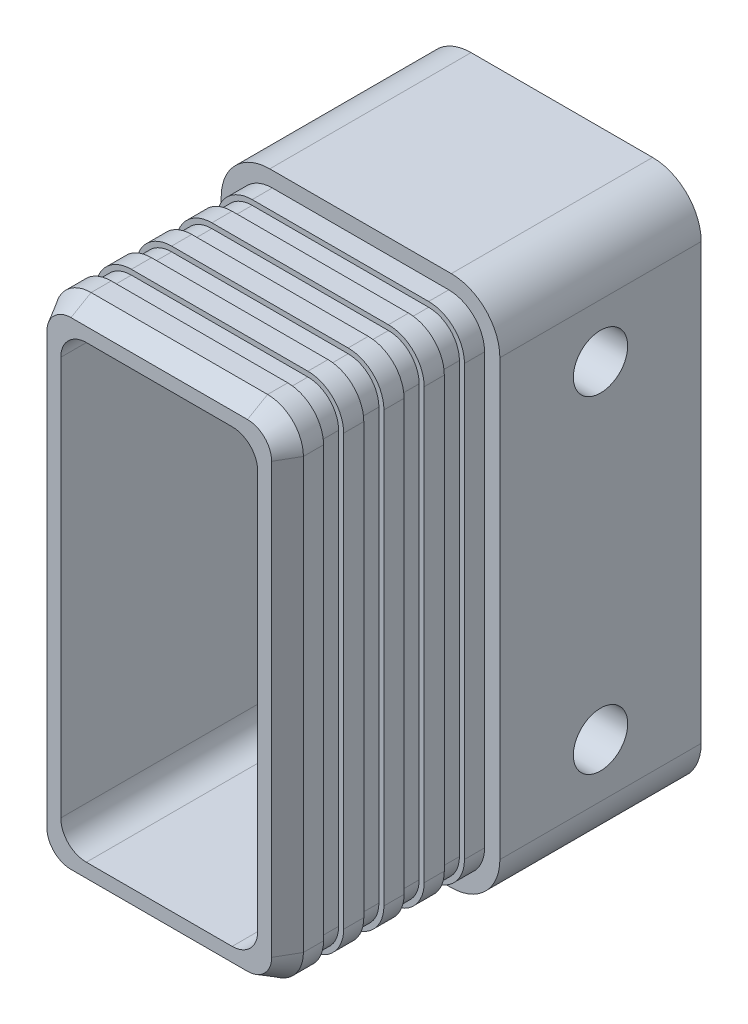
from build123d import *
from OCP.BRepFilletAPI import BRepFilletAPI_MakeChamfer

# Parameters (mm, degrees)
SKETCH1_W             = 24.646
SKETCH1_H             = 49.792
BOSS_EXTRUDE1_DEPTH   = 20
SKETCH2_W             = 27.686
SKETCH2_H             = 52.832
BOSS_EXTRUDE2_DEPTH   = 20
FILLET1_R             = 3.556
FILLET2_R             = 4.826
F_5_0MM_DOWEL_HOLE2_D = 5.4
CUT_EXTRUDE1_DEPTH    = 50.894225167
CUT_EXTRUDE2_START    = -4
CUT_EXTRUDE2_DEPTH    = 2
LPATTERN1_COUNT       = 4
LPATTERN1_PITCH       = 4
CHAMFER1_SIZE         = 2
CHAMFER1_SIZE2        = 1.154700538


with BuildPart() as part:
    # Sketch1 → Boss-Extrude1 (new body)
    with BuildSketch(Plane.XY):
        Rectangle(SKETCH1_W, SKETCH1_H)
    extrude(amount=BOSS_EXTRUDE1_DEPTH)

    # Sketch2 → Boss-Extrude2 (add)
    with BuildSketch(Plane.XY):
        Rectangle(SKETCH2_W, SKETCH2_H)
    extrude(amount=-BOSS_EXTRUDE2_DEPTH)

    # Fillet1
    fillet1_edges = [part.edges().sort_by_distance(p)[0] for p in [
        (-12.323, 24.896, 10),
        (12.323, 24.896, 10),
        (12.323, -24.896, 10),
        (-12.323, -24.896, 10),
    ]]
    fillet(fillet1_edges, radius=FILLET1_R)

    # Fillet2
    fillet2_edges = [part.edges().sort_by_distance(p)[0] for p in [
        (-13.843, -26.416, -10),
        (-13.843, 26.416, -10),
        (13.843, 26.416, -10),
        (13.843, -26.416, -10),
    ]]
    fillet(fillet2_edges, radius=FILLET2_R)

    # Ø5.0mm Dowel Hole2 (through all)
    with Locations(Plane(origin=(13.843, 0, 0), x_dir=(0, 0, -1), z_dir=(1, 0, 0))):
        with Locations((10, 16.256), (10, -16.256)):
            Hole(F_5_0MM_DOWEL_HOLE2_D / 2)

    # Sketch9 → Cut-Extrude1 (cut, through all)
    with BuildSketch(Plane.XY.offset(20)):
        with BuildLine():
            Line((7.243, -22.356), (-7.243, -22.356))
            ThreePointArc((-7.243, -22.356), (-9.039051224, -21.612051224), (-9.783, -19.816))
            Line((-9.783, -19.816), (-9.783, 19.816))
            ThreePointArc((-9.783, 19.816), (-9.039051224, 21.612051224), (-7.243, 22.356))
            Line((-7.243, 22.356), (7.243, 22.356))
            ThreePointArc((7.243, 22.356), (9.039051224, 21.612051224), (9.783, 19.816))
            Line((9.783, 19.816), (9.783, -19.816))
            ThreePointArc((9.783, -19.816), (9.039051224, -21.612051224), (7.243, -22.356))
        make_face()
    extrude(amount=-CUT_EXTRUDE1_DEPTH, mode=Mode.SUBTRACT)

    # Sketch10 → Cut-Extrude2 (cut)
    with BuildSketch(Plane.XY.offset(20).offset(CUT_EXTRUDE2_START)):
        with BuildLine():
            Line((-12.323, 21.34), (-12.323, -21.34))
            ThreePointArc((-12.323, -21.34), (-11.281471714, -23.854471714), (-8.767, -24.896))
            Line((-8.767, -24.896), (8.767, -24.896))
            ThreePointArc((8.767, -24.896), (11.281471714, -23.854471714), (12.323, -21.34))
            Line((12.323, -21.34), (12.323, 21.34))
            ThreePointArc((12.323, 21.34), (11.281471714, 23.854471714), (8.767, 24.896))
            Line((8.767, 24.896), (-8.767, 24.896))
            ThreePointArc((-8.767, 24.896), (-11.281471714, 23.854471714), (-12.323, 21.34))
        make_face()
        with BuildLine():
            Line((-11.823, 21.34), (-11.823, -21.34))
            ThreePointArc((-11.823, -21.34), (-10.927918323, -23.500918323), (-8.767, -24.396))
            Line((-8.767, -24.396), (8.767, -24.396))
            ThreePointArc((8.767, -24.396), (10.927918323, -23.500918323), (11.823, -21.34))
            Line((11.823, -21.34), (11.823, 21.34))
            ThreePointArc((11.823, 21.34), (10.927918323, 23.500918323), (8.767, 24.396))
            Line((8.767, 24.396), (-8.767, 24.396))
            ThreePointArc((-8.767, 24.396), (-10.927918323, 23.500918323), (-11.823, 21.34))
        make_face(mode=Mode.SUBTRACT)
    cut_extrude2 = extrude(amount=-CUT_EXTRUDE2_DEPTH, mode=Mode.SUBTRACT)

    # LPattern1: Cut-Extrude2 ×4
    with Locations(*[(0, 0, -i * LPATTERN1_PITCH) for i in range(1, LPATTERN1_COUNT)]):
        add(cut_extrude2, mode=Mode.SUBTRACT)

    # Chamfer1: one chamfer whose edges measure the first distance from different faces: ONE call of the kernel's chamfer builder (chamfer() names one face for all edges)
    chamfer1_edges_1 = [part.edges().sort_by_distance(p)[0] for p in [
        (0, -24.896, 20),
    ]]
    chamfer1_side_1 = [part.faces().sort_by_distance(p)[0] for p in [
        (0, -24.896, 18),
    ]]
    chamfer1_edges_2 = [part.edges().sort_by_distance(p)[0] for p in [
        (-12.323, 0, 20),
    ]]
    chamfer1_side_2 = [part.faces().sort_by_distance(p)[0] for p in [
        (-12.323, 0, 18),
    ]]
    chamfer1_edges_3 = [part.edges().sort_by_distance(p)[0] for p in [
        (12.323, 0, 20),
    ]]
    chamfer1_side_3 = [part.faces().sort_by_distance(p)[0] for p in [
        (12.323, 0, 18),
    ]]
    chamfer1_edges_4 = [part.edges().sort_by_distance(p)[0] for p in [
        (0, 24.896, 20),
    ]]
    chamfer1_side_4 = [part.faces().sort_by_distance(p)[0] for p in [
        (0, 24.896, 18),
    ]]
    chamfer1_edges_5 = [part.edges().sort_by_distance(p)[0] for p in [
        (-11.281471714, 23.854471714, 20),
    ]]
    chamfer1_side_5 = [part.faces().sort_by_distance(p)[0] for p in [
        (-11.281471714, 23.854471714, 18),
    ]]
    chamfer1_edges_6 = [part.edges().sort_by_distance(p)[0] for p in [
        (11.281471714, 23.854471714, 20),
    ]]
    chamfer1_side_6 = [part.faces().sort_by_distance(p)[0] for p in [
        (11.281471714, 23.854471714, 18),
    ]]
    chamfer1_edges_7 = [part.edges().sort_by_distance(p)[0] for p in [
        (11.281471714, -23.854471714, 20),
    ]]
    chamfer1_side_7 = [part.faces().sort_by_distance(p)[0] for p in [
        (11.281471714, -23.854471714, 18),
    ]]
    chamfer1_edges_8 = [part.edges().sort_by_distance(p)[0] for p in [
        (-11.281471714, -23.854471714, 20),
    ]]
    chamfer1_side_8 = [part.faces().sort_by_distance(p)[0] for p in [
        (-11.281471714, -23.854471714, 18),
    ]]
    chamfer1 = BRepFilletAPI_MakeChamfer(part.part.solid().wrapped)
    for e in chamfer1_edges_1:
        chamfer1.Add(CHAMFER1_SIZE, CHAMFER1_SIZE2, e.wrapped, chamfer1_side_1[0].wrapped)  # the first distance lies on this face
    for e in chamfer1_edges_2:
        chamfer1.Add(CHAMFER1_SIZE, CHAMFER1_SIZE2, e.wrapped, chamfer1_side_2[0].wrapped)  # the first distance lies on this face
    for e in chamfer1_edges_3:
        chamfer1.Add(CHAMFER1_SIZE, CHAMFER1_SIZE2, e.wrapped, chamfer1_side_3[0].wrapped)  # the first distance lies on this face
    for e in chamfer1_edges_4:
        chamfer1.Add(CHAMFER1_SIZE, CHAMFER1_SIZE2, e.wrapped, chamfer1_side_4[0].wrapped)  # the first distance lies on this face
    for e in chamfer1_edges_5:
        chamfer1.Add(CHAMFER1_SIZE, CHAMFER1_SIZE2, e.wrapped, chamfer1_side_5[0].wrapped)  # the first distance lies on this face
    for e in chamfer1_edges_6:
        chamfer1.Add(CHAMFER1_SIZE, CHAMFER1_SIZE2, e.wrapped, chamfer1_side_6[0].wrapped)  # the first distance lies on this face
    for e in chamfer1_edges_7:
        chamfer1.Add(CHAMFER1_SIZE, CHAMFER1_SIZE2, e.wrapped, chamfer1_side_7[0].wrapped)  # the first distance lies on this face
    for e in chamfer1_edges_8:
        chamfer1.Add(CHAMFER1_SIZE, CHAMFER1_SIZE2, e.wrapped, chamfer1_side_8[0].wrapped)  # the first distance lies on this face
    add(Compound.cast(chamfer1.Shape()), mode=Mode.REPLACE)


solid = part.part
